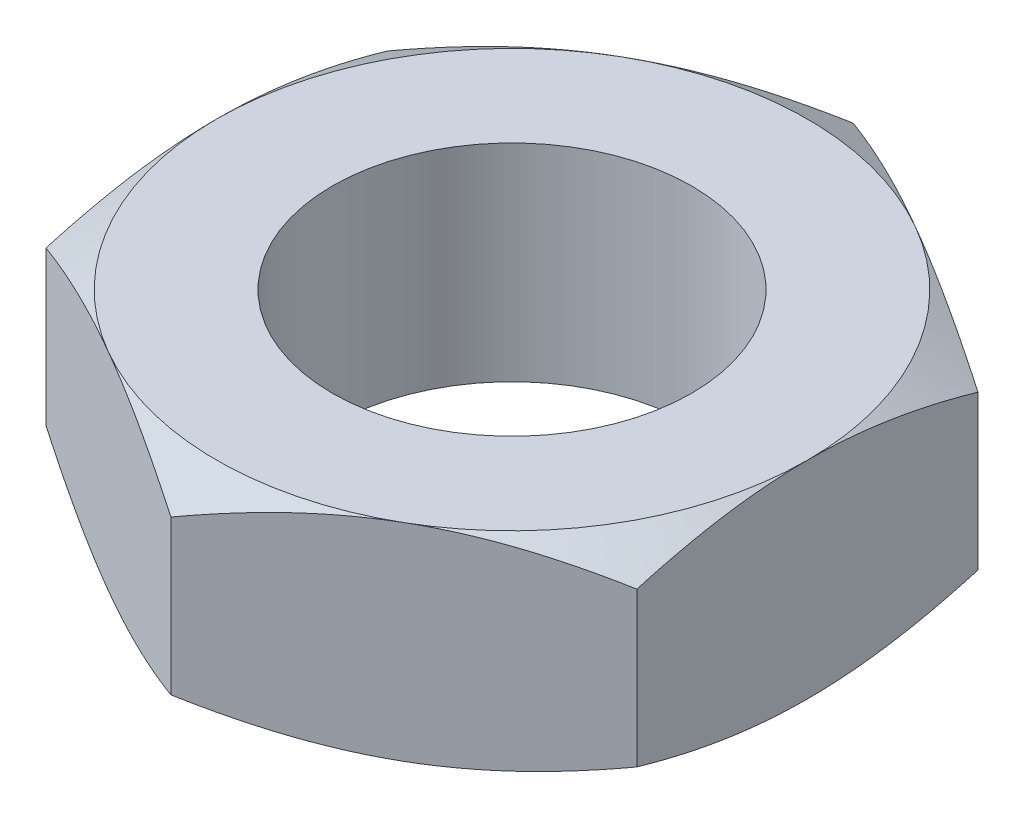
from build123d import *

# Parameters (mm, degrees)
SKETCH1_R           = 2.413
BOSS_EXTRUDE1_DEPTH = 1.3890625
SKETCH5_OUTSIDE_W   = 25.514
SKETCH5_OUTSIDE_H   = 26.742
SKETCH5_OUTSIDE_R   = 3.96875
CUT_EXTRUDE2_DEPTH  = 3.778125
CUT_EXTRUDE2_TAPER  = 60


with BuildPart() as part:
    # Sketch1 → Boss-Extrude1 (new body, symmetric)
    with BuildSketch(Plane(origin=(0, 0, 0), x_dir=(1, 0, 0), z_dir=(0, 1, 0))):
        Polygon((-3.96875, 2.291358881), (-3.96875, -2.291358881), (0, -4.582717762), (3.96875, -2.291358881), (3.96875, 2.291358881), (0, 4.582717762), align=None)
        Circle(SKETCH1_R, mode=Mode.SUBTRACT)
    extrude(amount=BOSS_EXTRUDE1_DEPTH, both=True)

    # Sketch5 outside → Cut-Extrude2 (cut, through all)
    with BuildSketch(Plane(origin=(0, 1.3890625, 0), x_dir=(1, 0, 0), z_dir=(0, 1, 0))):
        Rectangle(SKETCH5_OUTSIDE_W, SKETCH5_OUTSIDE_H)
        Circle(SKETCH5_OUTSIDE_R, mode=Mode.SUBTRACT)
    cut_extrude2 = extrude(amount=-CUT_EXTRUDE2_DEPTH, taper=CUT_EXTRUDE2_TAPER, mode=Mode.SUBTRACT)

    # Mirror1: Cut-Extrude2 across plane
    add(cut_extrude2.mirror(Plane.ZX), mode=Mode.SUBTRACT)


solid = part.part
